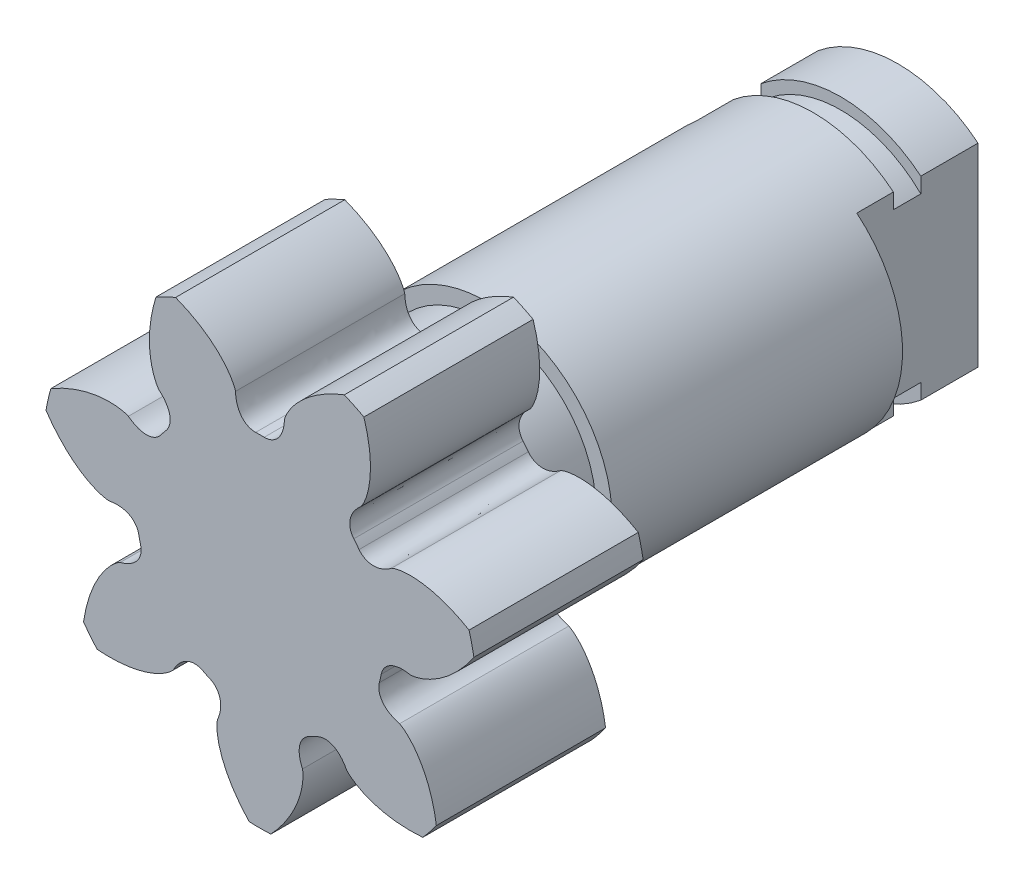
from build123d import *

# Parameters (mm, degrees)
GEAR_BASESKETCH_R                            = 9.5
F_2_0_MODULE_14_0000MM_P_D_DEPTH             = 3.7
TOOTH_CUT_COARSE_PITCH_INVOLUTE_20_DEG_DEPTH = 4.7
PATTERN_CIRCULAR_2_COUNT                     = 7
SKETCH_3_R                                   = 4.8
EXTRUDE_2_DEPTH                              = 2.5
SKETCH_5_R                                   = 5.5
EXTRUDE_3_DEPTH                              = 18
CUT_EXTRUDE_2_DEPTH                          = 5.3
SKETCH_7_R                                   = 3
CUT_EXTRUDE_3_DEPTH                          = 7
SKETCH_8_W                                   = 1.2
SKETCH_8_H                                   = 0.5


with BuildPart() as part:
    # Gear-BaseSketch → 2.0 Module, 14,0000mm P.D. (new body, symmetric)
    with BuildSketch(Plane.XY):
        Circle(GEAR_BASESKETCH_R)
    extrude(amount=F_2_0_MODULE_14_0000MM_P_D_DEPTH, both=True)

    # Tooth-Sketch; Backlash: 0,0000mm → Tooth-Cut, Coarse Pitch Involute 20 deg (cut, symmetric)
    with BuildSketch(Plane.XY):
        with BuildLine():
            ThreePointArc((-4.327151416, 8.965203263), (0, 9.954853536), (4.327151416, 8.965203263))
            add(Edge.make_bspline(
                [(1.069128487, 6.507747849), (1.072044727, 6.520167615), (1.078269742, 6.542473004), (1.089212472, 6.576617818), (1.102022576, 6.612514218), (1.118514754, 6.65442894), (1.139097912, 6.702151935), (1.164160902, 6.755455873), (1.194085322, 6.814093445), (1.229240125, 6.877798869), (1.269982283, 6.946288043), (1.316655525, 7.019259185), (1.369589716, 7.096393358), (1.42910006, 7.17735507), (1.495486393, 7.261792894), (1.569032482, 7.349340116), (1.650005354, 7.43961542), (1.738654649, 7.532223587), (1.835212008, 7.626756232), (1.939890485, 7.72279256), (2.05288399, 7.819900147), (2.174366767, 7.917635747), (2.304492899, 8.015546115), (2.443395848, 8.113168853), (2.591188035, 8.210033279), (2.747960441, 8.305661307), (2.91378226, 8.399568348), (3.088700571, 8.491264224), (3.272740056, 8.580254099), (3.465902784, 8.66603941), (3.668167864, 8.74811885), (3.954267985, 8.853543351), (4.175883188, 8.922984976), (4.327151416, 8.965203263)],
                knots=[0, 0, 0, 0, 0.009053938, 0.016430709, 0.025446762, 0.036102096, 0.048396713, 0.062330612, 0.077903793, 0.095116256, 0.113968001, 0.134459028, 0.156589337, 0.180358929, 0.205767802, 0.232815958, 0.261503395, 0.291830115, 0.323796117, 0.357401401, 0.392645967, 0.429529815, 0.468052946, 0.508215358, 0.550017053, 0.59345803, 0.638538288, 0.685257829, 0.733616653, 0.783614758, 0.835252145, 0.888528815, 1, 1, 1, 1], degree=3))
            add(Edge.make_bspline(
                [(1.069128487, 6.507747849), (1.067264089, 6.441009339), (1.057322814, 6.311596337), (1.021337773, 6.12292024), (0.962143651, 5.943326066), (0.872169877, 5.769108483), (0.736659423, 5.601380797), (0.512827884, 5.439448912), (0.307138196, 5.394374651), (0.18568221, 5.396806659)],
                knots=[0, 0, 0, 0, 0.126566916, 0.245964835, 0.363426606, 0.484114544, 0.615986694, 0.769025676, 1, 1, 1, 1], degree=3))
            ThreePointArc((0.18568221, 5.396806659), (0, 5.4), (-0.18568221, 5.396806659))
            add(Edge.make_bspline(
                [(-1.069128487, 6.507747849), (-1.067264089, 6.441009339), (-1.057322814, 6.311596337), (-1.021337773, 6.12292024), (-0.962143651, 5.943326066), (-0.872169877, 5.769108483), (-0.736659423, 5.601380797), (-0.512827884, 5.439448912), (-0.307138196, 5.394374651), (-0.18568221, 5.396806659)],
                knots=[0, 0, 0, 0, 0.126566916, 0.245964835, 0.363426606, 0.484114544, 0.615986694, 0.769025676, 1, 1, 1, 1], degree=3))
            add(Edge.make_bspline(
                [(-1.069128487, 6.507747849), (-1.072044727, 6.520167615), (-1.078269742, 6.542473004), (-1.089212472, 6.576617818), (-1.102022576, 6.612514218), (-1.118514754, 6.65442894), (-1.139097912, 6.702151935), (-1.164160902, 6.755455873), (-1.194085322, 6.814093445), (-1.229240125, 6.877798869), (-1.269982283, 6.946288043), (-1.316655525, 7.019259185), (-1.369589716, 7.096393358), (-1.42910006, 7.17735507), (-1.495486393, 7.261792894), (-1.569032482, 7.349340116), (-1.650005354, 7.43961542), (-1.738654649, 7.532223587), (-1.835212008, 7.626756232), (-1.939890485, 7.72279256), (-2.05288399, 7.819900147), (-2.174366767, 7.917635747), (-2.304492899, 8.015546115), (-2.443395848, 8.113168853), (-2.591188035, 8.210033279), (-2.747960441, 8.305661307), (-2.91378226, 8.399568348), (-3.088700571, 8.491264224), (-3.272740056, 8.580254099), (-3.465902784, 8.66603941), (-3.668167864, 8.74811885), (-3.954267985, 8.853543351), (-4.175883188, 8.922984976), (-4.327151416, 8.965203263)],
                knots=[0, 0, 0, 0, 0.009053938, 0.016430709, 0.025446762, 0.036102096, 0.048396713, 0.062330612, 0.077903793, 0.095116256, 0.113968001, 0.134459028, 0.156589337, 0.180358929, 0.205767802, 0.232815958, 0.261503395, 0.291830115, 0.323796117, 0.357401401, 0.392645967, 0.429529815, 0.468052946, 0.508215358, 0.550017053, 0.59345803, 0.638538288, 0.685257829, 0.733616653, 0.783614758, 0.835252145, 0.888528815, 1, 1, 1, 1], degree=3))
        make_face()
    tooth_cut_coarse_pitch_involute_20_deg = extrude(amount=TOOTH_CUT_COARSE_PITCH_INVOLUTE_20_DEG_DEPTH, both=True, mode=Mode.SUBTRACT)

    # Круговой массив2: Tooth-Cut, Coarse Pitch Involute 20 deg ×7 about axis
    pattern_circular_2_axis = Axis((0, 0, -88.99), (0, 0, 1))
    for i in range(1, PATTERN_CIRCULAR_2_COUNT):
        add(tooth_cut_coarse_pitch_involute_20_deg.rotate(pattern_circular_2_axis, i * 360 / PATTERN_CIRCULAR_2_COUNT), mode=Mode.SUBTRACT)

    # Эскиз3 → Бобышка-Вытянуть2 (add)
    with BuildSketch(Plane(origin=(0, 0, -3.7), x_dir=(-1, 0, 0), z_dir=(0, 0, -1))):
        Circle(SKETCH_3_R)
    extrude(amount=EXTRUDE_2_DEPTH)

    # Эскиз5 → Бобышка-Вытянуть3 (add)
    with BuildSketch(Plane(origin=(0, 0, -6.2), x_dir=(-1, 0, 0), z_dir=(0, 0, -1))):
        Circle(SKETCH_5_R)
    extrude(amount=EXTRUDE_3_DEPTH)

    # Эскиз6 → Вырез-Вытянуть2 (cut)
    with BuildSketch(Plane(origin=(0, 0, -24.2), x_dir=(-1, 0, 0), z_dir=(0, 0, -1))):
        with BuildLine():
            Line((-3.5, 4.242640687), (-3.5, -4.242640687))
            ThreePointArc((-3.5, -4.242640687), (-5.5, 0), (-3.5, 4.242640687))
        make_face()
        with BuildLine():
            Line((3.5, 4.242640687), (3.5, -4.242640687))
            ThreePointArc((3.5, -4.242640687), (5.5, 0), (3.5, 4.242640687))
        make_face()
    extrude(amount=-CUT_EXTRUDE_2_DEPTH, mode=Mode.SUBTRACT)

    # Эскиз7 → Вырез-Вытянуть3 (cut)
    with BuildSketch(Plane(origin=(0, 0, -24.2), x_dir=(-1, 0, 0), z_dir=(0, 0, -1))):
        Circle(SKETCH_7_R)
    extrude(amount=-CUT_EXTRUDE_3_DEPTH, mode=Mode.SUBTRACT)

    # Эскиз8 → Вырез-Повернуть1 (revolve, cut)
    with BuildSketch(Plane(origin=(0, 0, 0), x_dir=(0, 0, -1), z_dir=(1, 0, 0))):
        with Locations((21.1, 5.25)):
            Rectangle(SKETCH_8_W, SKETCH_8_H)
    revolve(axis=Axis((0, 0, 0), (0, 0, -1)), mode=Mode.SUBTRACT)


solid = part.part
